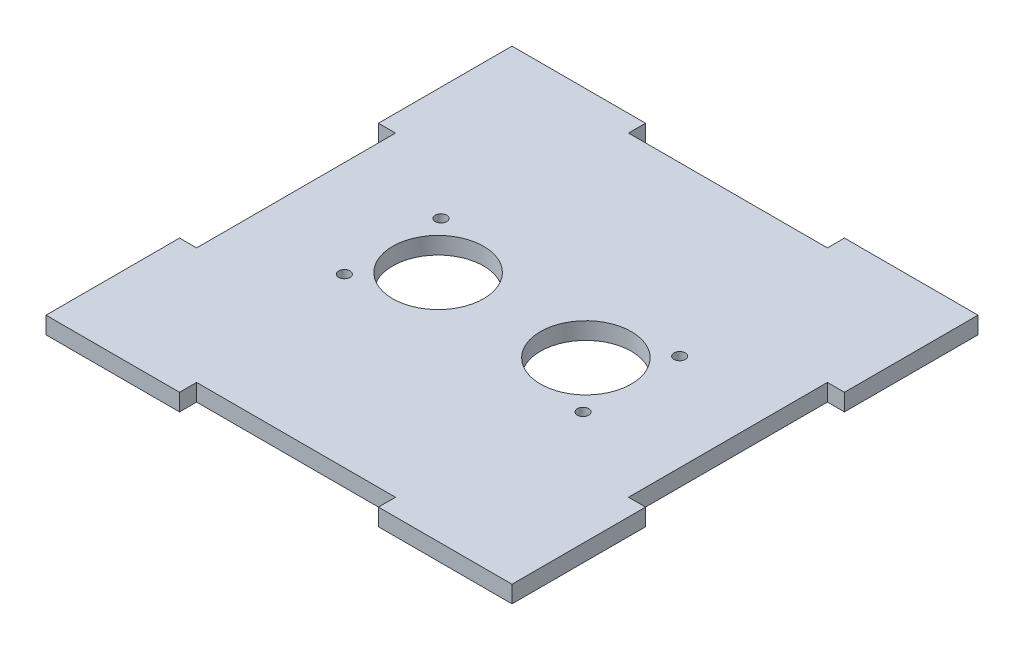
from build123d import *

# Parameters (mm, degrees)
BOSS_EXTRUDE1_DEPTH = 3
SKETCH2_R           = 8
SKETCH2_R_2         = 1
CUT_EXTRUDE1_DEPTH  = 3


with BuildPart() as part:
    # Sketch1 → Boss-Extrude1 (new body)
    with BuildSketch(Plane(origin=(0, 0, 0), x_dir=(1, 0, 0), z_dir=(0, 1, 0))):
        Polygon((-41, -41), (-17.5, -41), (-17.5, -38), (17.5, -38), (17.5, -41), (41, -41), (41, -17.5), (38, -17.5), (38, 17.5), (41, 17.5), (41, 41), (17.5, 41), (17.5, 38), (-17.5, 38), (-17.5, 41), (-41, 41), (-41, 17.5), (-38, 17.5), (-38, -17.5), (-41, -17.5), align=None)
    extrude(amount=BOSS_EXTRUDE1_DEPTH)

    # Sketch2 → Cut-Extrude1 (cut)
    with BuildSketch(Plane(origin=(0, 3, 0), x_dir=(1, 0, 0), z_dir=(0, 1, 0))):
        with Locations((-13, 0)):
            Circle(SKETCH2_R)
        with Locations((-21, 8.5)):
            Circle(SKETCH2_R_2)
        with Locations((-21, -8.5)):
            Circle(SKETCH2_R_2)
        with Locations((21, -8.5)):
            Circle(SKETCH2_R_2)
        with Locations((21, 8.5)):
            Circle(SKETCH2_R_2)
        with Locations((13, 0)):
            Circle(SKETCH2_R)
    extrude(amount=-CUT_EXTRUDE1_DEPTH, mode=Mode.SUBTRACT)


solid = part.part
